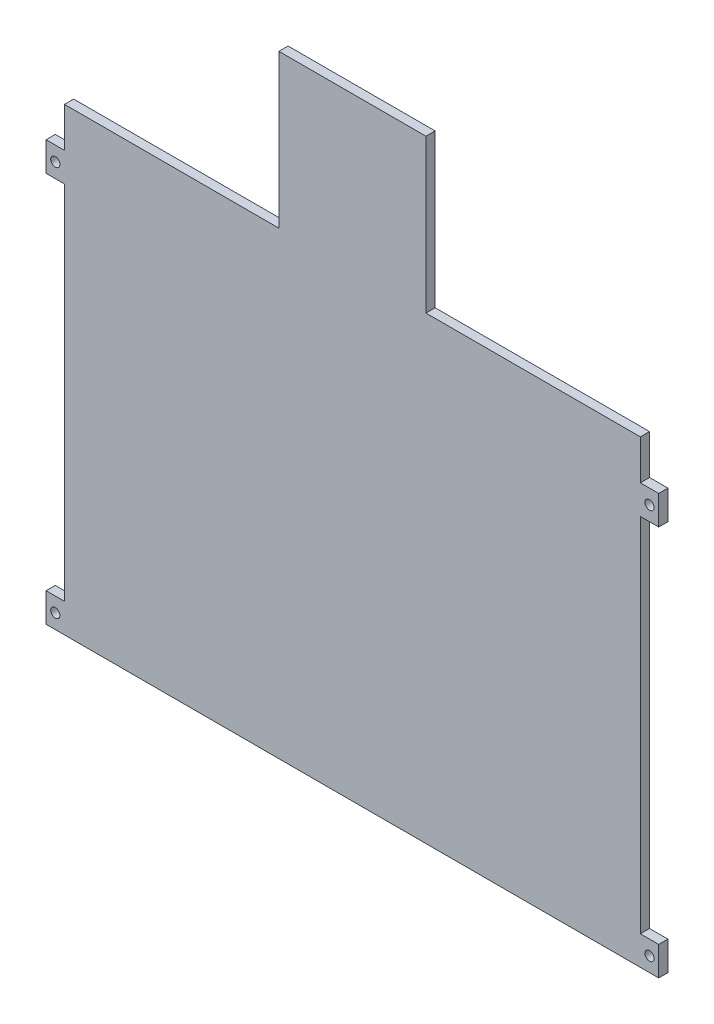
from build123d import *

# Parameters (mm, degrees)
ESBO_O1_R                = 1.5
RESSALTO_EXTRUS_O1_DEPTH = 3


with BuildPart() as part:
    # Esboço1 → Ressalto-extrusão1 (new body)
    with BuildSketch(Plane.XY):
        Polygon((-24, 100), (24, 100), (24, 50), (94, 50), (94, 37), (100, 37), (100, 27.5), (94, 27.5), (94, -90.5), (100, -90.5), (100, -100), (94, -100), (-94, -100), (-100, -100), (-100, -90.5), (-94, -90.5), (-94, 27.5), (-100, 27.5), (-100, 37), (-94, 37), (-94, 50), (-24, 50), align=None)
        with Locations((97, -95.25)):
            Circle(ESBO_O1_R, mode=Mode.SUBTRACT)
        with Locations((97, 32.25)):
            Circle(ESBO_O1_R, mode=Mode.SUBTRACT)
        with Locations((-97, 32.25)):
            Circle(ESBO_O1_R, mode=Mode.SUBTRACT)
        with Locations((-97, -95.25)):
            Circle(ESBO_O1_R, mode=Mode.SUBTRACT)
    extrude(amount=RESSALTO_EXTRUS_O1_DEPTH)


solid = part.part
